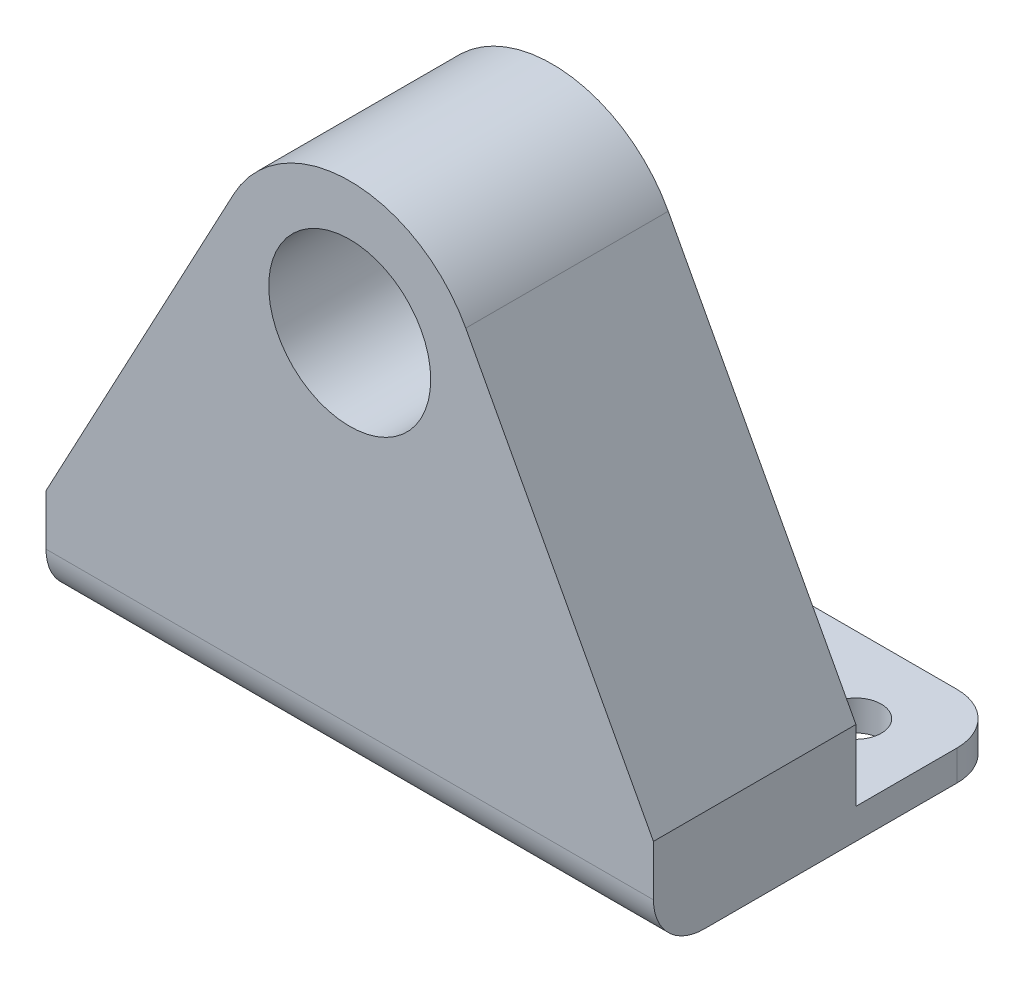
from build123d import *

# Parameters (mm, degrees)
SKETCH1_R           = 8
BOSS_EXTRUDE1_DEPTH = 20
SKETCH2_W           = 60
SKETCH2_H           = 3
BOSS_EXTRUDE2_DEPTH = 15
SKETCH3_R           = 2.5
CUT_EXTRUDE1_DEPTH  = 20
FILLET1_R           = 5


with BuildPart() as part:
    # Sketch1 → Boss-Extrude1 (new body)
    with BuildSketch(Plane.XY):
        with BuildLine():
            Line((30, -28.5), (30, -38.5))
            Line((30, -38.5), (-30, -38.5))
            Line((-30, -38.5), (-30, -28.5))
            Line((-30, -28.5), (-11.461412637, 6.13482032))
            ThreePointArc((-11.461412637, 6.13482032), (0, 13), (11.461412637, 6.13482032))
            Line((11.461412637, 6.13482032), (30, -28.5))
        make_face()
        Circle(SKETCH1_R, mode=Mode.SUBTRACT)
    extrude(amount=BOSS_EXTRUDE1_DEPTH)

    # Sketch2 → Boss-Extrude2 (add)
    with BuildSketch(Plane(origin=(0, 0, 0), x_dir=(-1, 0, 0), z_dir=(0, 0, -1))):
        with Locations((0, -37)):
            Rectangle(SKETCH2_W, SKETCH2_H)
    extrude(amount=BOSS_EXTRUDE2_DEPTH)

    # Sketch3 → Cut-Extrude1 (cut)
    with BuildSketch(Plane.XZ.offset(38.5)):
        with Locations((22.5, -7.5)):
            Circle(SKETCH3_R)
        with Locations((-22.5, -7.5)):
            Circle(SKETCH3_R)
    extrude(amount=-CUT_EXTRUDE1_DEPTH, mode=Mode.SUBTRACT)

    # Fillet1
    fillet1_edges = [part.edges().sort_by_distance(p)[0] for p in [
        (30, -37, -15),
        (-30, -37, -15),
        (0, -38.5, 20),
    ]]
    fillet(fillet1_edges, radius=FILLET1_R)


solid = part.part
